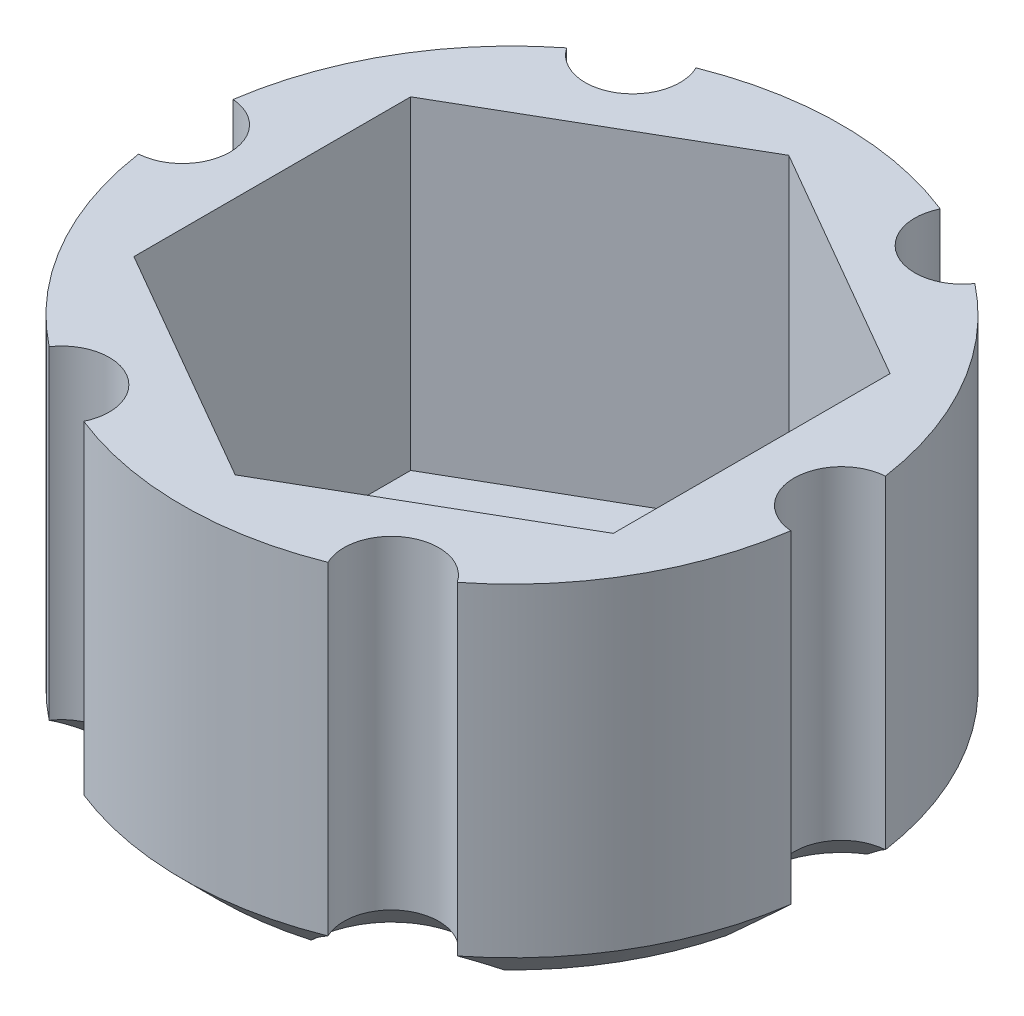
from build123d import *

# Parameters (mm, degrees)
SKETCH1_R           = 5.5
BOSS_EXTRUDE1_DEPTH = 6
CUT_EXTRUDE1_START  = 6
CUT_EXTRUDE1_DEPTH  = 5.4
SKETCH3_R           = 0.791791972
CUT_EXTRUDE2_DEPTH  = 6
CHAMFER1_SIZE       = 0.6


with BuildPart() as part:
    # Sketch1 → Boss-Extrude1 (new body)
    with BuildSketch(Plane(origin=(0, 0, 0), x_dir=(1, 0, 0), z_dir=(0, 1, 0))):
        Circle(SKETCH1_R)
    extrude(amount=BOSS_EXTRUDE1_DEPTH)

    # Sketch2 → Cut-Extrude1 (cut)
    with BuildSketch(Plane(origin=(0, 0, 0), x_dir=(1, 0, 0), z_dir=(0, 1, 0)).offset(CUT_EXTRUDE1_START)):
        Polygon((4, -2.309401077), (4, 2.309401077), (0, 4.618802154), (-4, 2.309401077), (-4, -2.309401077), (0, -4.618802154), align=None)
    extrude(amount=-CUT_EXTRUDE1_DEPTH, mode=Mode.SUBTRACT)

    # Sketch3 → Cut-Extrude2 (cut)
    with BuildSketch(Plane(origin=(0, 0, 0), x_dir=(1, 0, 0), z_dir=(0, 1, 0))):
        with Locations((-5.5, 0)):
            Circle(SKETCH3_R)
        with Locations((-2.75, 4.763139721)):
            Circle(SKETCH3_R)
        with Locations((2.75, 4.763139721)):
            Circle(SKETCH3_R)
        with Locations((5.5, 0)):
            Circle(SKETCH3_R)
        with Locations((2.75, -4.763139721)):
            Circle(SKETCH3_R)
        with Locations((-2.75, -4.763139721)):
            Circle(SKETCH3_R)
    extrude(amount=CUT_EXTRUDE2_DEPTH, mode=Mode.SUBTRACT)

    # Chamfer1
    chamfer1_edges = [part.edges().sort_by_distance(p)[0] for p in [
        (4.763139721, 0, 2.75),
        (4.763139721, 0, -2.75),
        (0, 0, -5.5),
        (-4.763139721, 0, -2.75),
        (-4.763139721, 0, 2.75),
        (0, 0, 5.5),
        (-2.354104014, 0, -4.077427759),
        (2.354104014, 0, -4.077427759),
        (-4.708208028, 0, 0),
        (-2.354104014, 0, 4.077427759),
        (2.354104014, 0, 4.077427759),
        (4.708208028, 0, 0),
    ]]
    chamfer(chamfer1_edges, length=CHAMFER1_SIZE)


solid = part.part
